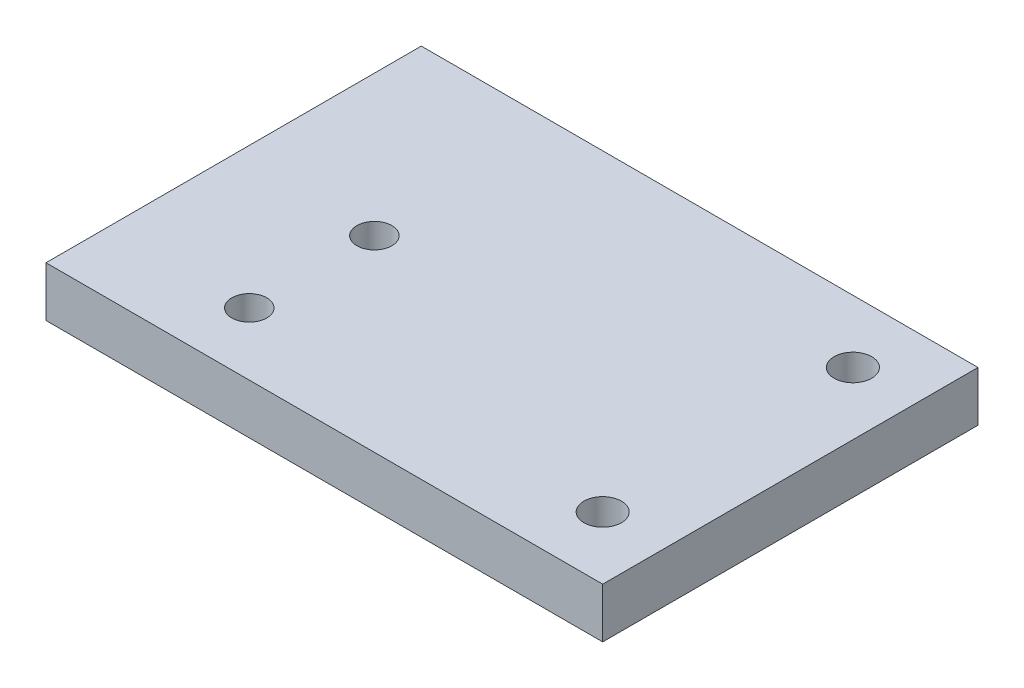
from build123d import *

# Parameters (mm, degrees)
SKETCH1_W           = 22.5
SKETCH1_H           = 30
SKETCH1_R           = 1.4
SKETCH1_W_2         = 22
SKETCH1_R_2         = 1.5
BOSS_EXTRUDE1_DEPTH = 4


with BuildPart() as part:
    # Sketch1 → Boss-Extrude1 (new body)
    with BuildSketch(Plane(origin=(0, 0, 0), x_dir=(1, 0, 0), z_dir=(0, 1, 0))):
        with Locations((11.25, 15)):
            Rectangle(SKETCH1_W, SKETCH1_H)
        with Locations((11.25, 5)):
            Circle(SKETCH1_R, mode=Mode.SUBTRACT)
        with Locations((11.25, 15)):
            Circle(SKETCH1_R, mode=Mode.SUBTRACT)
        with Locations((33.5, 15)):
            Rectangle(SKETCH1_W_2, SKETCH1_H)
        with Locations((39.5, 5)):
            Circle(SKETCH1_R_2, mode=Mode.SUBTRACT)
        with Locations((39.5, 25)):
            Circle(SKETCH1_R_2, mode=Mode.SUBTRACT)
    extrude(amount=BOSS_EXTRUDE1_DEPTH)


solid = part.part
